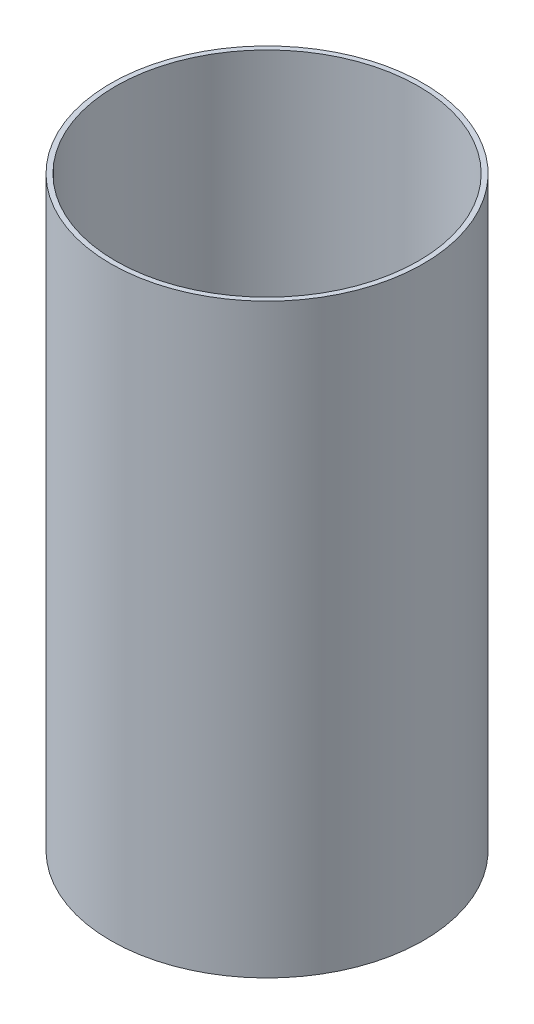
from build123d import *

# Parameters (mm, degrees)
SKETCH1_R           = 101.6
SKETCH1_R_2         = 98.425
BOSS_EXTRUDE1_DEPTH = 381


with BuildPart() as part:
    # Sketch1 → Boss-Extrude1 (new body)
    with BuildSketch(Plane(origin=(0, 0, 0), x_dir=(1, 0, 0), z_dir=(0, 1, 0))):
        Circle(SKETCH1_R)
        Circle(SKETCH1_R_2, mode=Mode.SUBTRACT)
    extrude(amount=BOSS_EXTRUDE1_DEPTH)


solid = part.part
